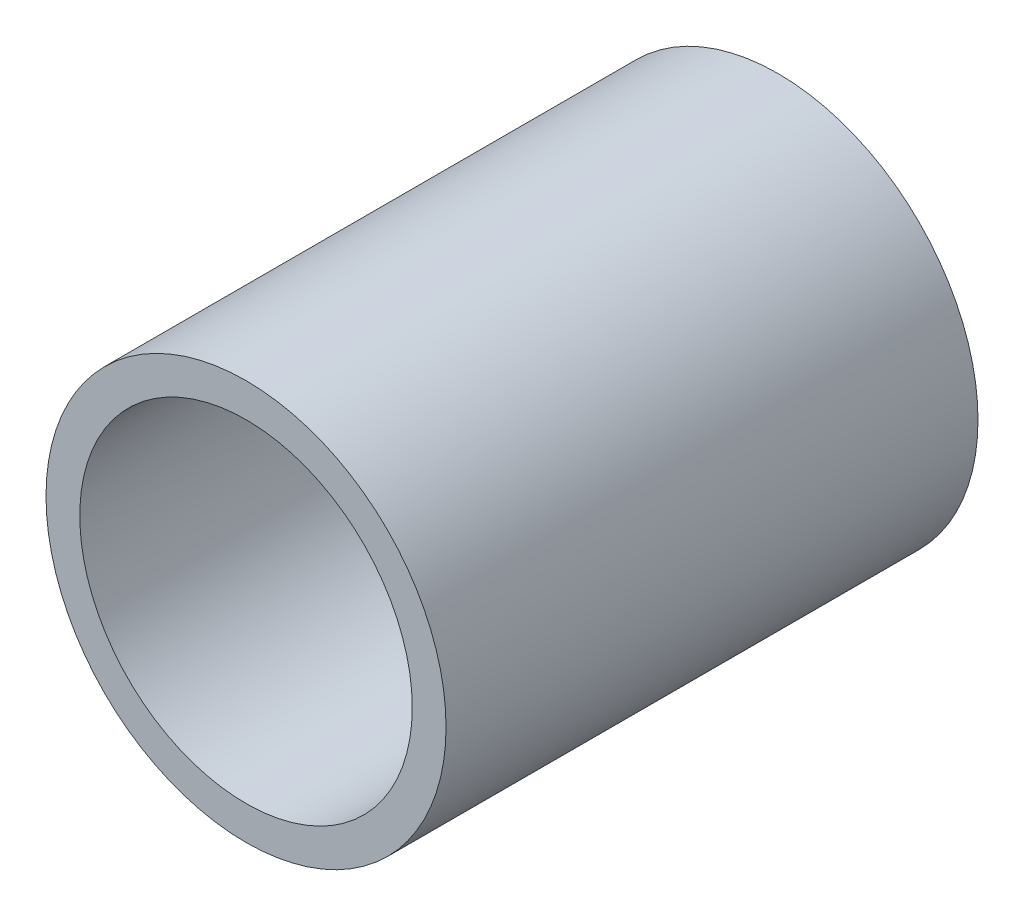
from build123d import *

# Parameters (mm, degrees)
SKETCH1_R      = 4.7752
SKETCH1_R_2    = 3.96875
EXTRUDE1_DEPTH = 6.35


with BuildPart() as part:
    # Sketch1 → Extrude1 (new body, symmetric)
    with BuildSketch(Plane.XY):
        Circle(SKETCH1_R)
        Circle(SKETCH1_R_2, mode=Mode.SUBTRACT)
    extrude(amount=EXTRUDE1_DEPTH, both=True)


solid = part.part
